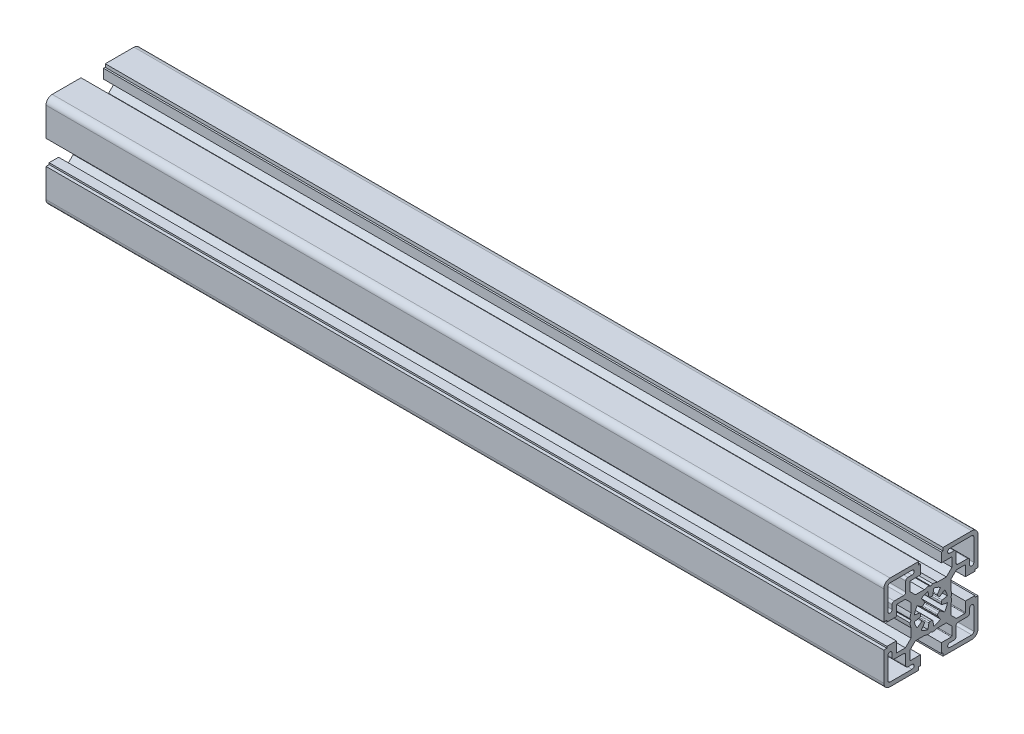
from build123d import *

# Parameters (mm, degrees)
EXTRUDE_1_DEPTH     = 400
CUT_EXTRUDE_1_DEPTH = 401


with BuildPart() as part:
    # Эскиз2 → Бобышка-Вытянуть1 (new body)
    with BuildSketch(Plane(origin=(0, 0, 0), x_dir=(0, 0, -1), z_dir=(1, 0, 0))):
        with BuildLine():
            Line((16.5, 5), (21, 5))
            Line((21, 5), (21, 5.799999))
            Line((21, 5.799999), (22.5, 5.799999))
            Line((22.5, 5.799999), (22.5, 19.5))
            ThreePointArc((22.5, 19.5), (21.621320344, 21.621320344), (19.5, 22.5))
            Line((19.5, 22.5), (5.799999, 22.5))
            Line((5.799999, 22.5), (5.799999, 21))
            Line((5.799999, 21), (5, 21))
            Line((5, 21), (5, 16.5))
            Line((5, 16.5), (9.75, 16.5))
            ThreePointArc((9.75, 16.5), (9.962132034, 16.412132034), (10.05, 16.2))
            Line((10.05, 16.2), (10.05, 12.171320344))
            Line((10.05, 12.171320344), (7.378679656, 9.5))
            Line((7.378679656, 9.5), (3.122498999, 9.5))
            ThreePointArc((3.122498999, 9.5), (2.007620973, 9.796400259), (0.866025404, 9.962429423))
            Line((0.866025404, 9.962429423), (0, 9.462429423))
            Line((0, 9.462429423), (-0.866025404, 9.962429423))
            ThreePointArc((-0.866025404, 9.962429423), (-2.007620973, 9.796400259), (-3.122498999, 9.5))
            Line((-3.122498999, 9.5), (-7.378679656, 9.5))
            Line((-7.378679656, 9.5), (-10.049999, 12.171319344))
            Line((-10.049999, 12.171319344), (-10.049999, 16.2))
            ThreePointArc((-10.049999, 16.2), (-9.962131034, 16.412132034), (-9.749999, 16.5))
            Line((-9.749999, 16.5), (-5, 16.5))
            Line((-5, 16.5), (-5, 21))
            Line((-5, 21), (-5.799999, 21))
            Line((-5.799999, 21), (-5.799999, 22.5))
            Line((-5.799999, 22.5), (-19.5, 22.5))
            ThreePointArc((-19.5, 22.5), (-21.621320344, 21.621320344), (-22.5, 19.5))
            Line((-22.5, 19.5), (-22.5, 5.799999))
            Line((-22.5, 5.799999), (-21, 5.799999))
            Line((-21, 5.799999), (-21, 5))
            Line((-21, 5), (-16.5, 5))
            Line((-16.5, 5), (-16.5, 9.749999))
            ThreePointArc((-16.5, 9.749999), (-16.412132034, 9.962131034), (-16.2, 10.049999))
            Line((-16.2, 10.049999), (-12.171319344, 10.049999))
            Line((-12.171319344, 10.049999), (-9.5, 7.378679656))
            Line((-9.5, 7.378679656), (-9.5, 3.122498999))
            ThreePointArc((-9.5, 3.122498999), (-9.796400259, 2.007620973), (-9.962429423, 0.866025404))
            Line((-9.962429423, 0.866025404), (-9.462429423, 0))
            Line((-9.462429423, 0), (-9.962429423, -0.866025404))
            ThreePointArc((-9.962429423, -0.866025404), (-9.796400259, -2.007620973), (-9.5, -3.122498999))
            Line((-9.5, -3.122498999), (-9.5, -7.378679656))
            Line((-9.5, -7.378679656), (-12.171320344, -10.05))
            Line((-12.171320344, -10.05), (-16.2, -10.05))
            ThreePointArc((-16.2, -10.05), (-16.412132034, -9.962132034), (-16.5, -9.75))
            Line((-16.5, -9.75), (-16.5, -5))
            Line((-16.5, -5), (-21, -5))
            Line((-21, -5), (-21, -5.799999))
            Line((-21, -5.799999), (-22.5, -5.799999))
            Line((-22.5, -5.799999), (-22.5, -19.5))
            ThreePointArc((-22.5, -19.5), (-21.621320344, -21.621320344), (-19.5, -22.5))
            Line((-19.5, -22.5), (-5.799999, -22.5))
            Line((-5.799999, -22.5), (-5.799999, -21))
            Line((-5.799999, -21), (-5, -21))
            Line((-5, -21), (-5, -16.5))
            Line((-5, -16.5), (-9.749999, -16.5))
            ThreePointArc((-9.749999, -16.5), (-9.962131034, -16.412132034), (-10.049999, -16.2))
            Line((-10.049999, -16.2), (-10.049999, -12.171319344))
            Line((-10.049999, -12.171319344), (-7.378679656, -9.5))
            Line((-7.378679656, -9.5), (-3.122498999, -9.5))
            ThreePointArc((-3.122498999, -9.5), (-2.007620973, -9.796400259), (-0.866025404, -9.962429423))
            Line((-0.866025404, -9.962429423), (0, -9.462429423))
            Line((0, -9.462429423), (0.866025404, -9.962429423))
            ThreePointArc((0.866025404, -9.962429423), (2.007620973, -9.796400259), (3.122498999, -9.5))
            Line((3.122498999, -9.5), (7.378679656, -9.5))
            Line((7.378679656, -9.5), (10.05, -12.171320344))
            Line((10.05, -12.171320344), (10.05, -16.2))
            ThreePointArc((10.05, -16.2), (9.962132034, -16.412132034), (9.75, -16.5))
            Line((9.75, -16.5), (5, -16.5))
            Line((5, -16.5), (5, -21))
            Line((5, -21), (5.799999, -21))
            Line((5.799999, -21), (5.799999, -22.5))
            Line((5.799999, -22.5), (19.5, -22.5))
            ThreePointArc((19.5, -22.5), (21.621320344, -21.621320344), (22.5, -19.5))
            Line((22.5, -19.5), (22.5, -5.799999))
            Line((22.5, -5.799999), (21, -5.799999))
            Line((21, -5.799999), (21, -5))
            Line((21, -5), (16.5, -5))
            Line((16.5, -5), (16.5, -9.75))
            ThreePointArc((16.5, -9.75), (16.412132034, -9.962132034), (16.2, -10.05))
            Line((16.2, -10.05), (12.171320344, -10.05))
            Line((12.171320344, -10.05), (9.5, -7.378679656))
            Line((9.5, -7.378679656), (9.5, -3.122498999))
            ThreePointArc((9.5, -3.122498999), (9.796400259, -2.007620973), (9.962429423, -0.866025404))
            Line((9.962429423, -0.866025404), (9.462429423, 0))
            Line((9.462429423, 0), (9.962429423, 0.866025404))
            ThreePointArc((9.962429423, 0.866025404), (9.796400259, 2.007620973), (9.5, 3.122498999))
            Line((9.5, 3.122498999), (9.5, 7.378679656))
            Line((9.5, 7.378679656), (12.171319344, 10.049999))
            Line((12.171319344, 10.049999), (16.2, 10.049999))
            ThreePointArc((16.2, 10.049999), (16.412132034, 9.962131034), (16.5, 9.749999))
            Line((16.5, 9.749999), (16.5, 5))
        make_face()
    extrude(amount=EXTRUDE_1_DEPTH)

    # Эскиз3 → Вырез-Вытянуть1 (cut, through all)
    with BuildSketch(Plane.ZY):
        with BuildLine():
            Line((-0.951109584, 5.394014463), (-1.38918508, 7.878462452))
            ThreePointArc((-1.38918508, 7.878462452), (-3.061467429, 7.391036664), (-4.588611737, 6.553216624))
            Line((-4.588611737, 6.553216624), (-3.14160736, 4.486680308))
            ThreePointArc((-3.14160736, 4.486680308), (-3.055338858, 4.135563126), (-3.228348507, 3.81808369))
            ThreePointArc((-3.228348507, 3.81808369), (-3.535533704, 3.535533704), (-3.81808369, 3.228348507))
            ThreePointArc((-3.81808369, 3.228348507), (-4.135563126, 3.055338858), (-4.486680308, 3.14160736))
            Line((-4.486680308, 3.14160736), (-6.553216624, 4.588611737))
            ThreePointArc((-6.553216624, 4.588611737), (-7.391036664, 3.061467429), (-7.878462452, 1.38918508))
            Line((-7.878462452, 1.38918508), (-5.394014463, 0.951109584))
            ThreePointArc((-5.394014463, 0.951109584), (-5.084736142, 0.763833295), (-4.982580573, 0.417005199))
            ThreePointArc((-4.982580573, 0.417005199), (-5.000000251, 0), (-4.982580573, -0.417005199))
            ThreePointArc((-4.982580573, -0.417005199), (-5.084736142, -0.763833295), (-5.394014463, -0.951109584))
            Line((-5.394014463, -0.951109584), (-7.878461766, -1.389184959))
            ThreePointArc((-7.878461766, -1.389184959), (-7.391036076, -3.06146703), (-6.553216219, -4.588611102))
            Line((-6.553216219, -4.588611102), (-4.486680308, -3.14160736))
            ThreePointArc((-4.486680308, -3.14160736), (-4.135563126, -3.055338858), (-3.81808369, -3.228348507))
            ThreePointArc((-3.81808369, -3.228348507), (-3.535533733, -3.535533675), (-3.22834857, -3.818083636))
            ThreePointArc((-3.22834857, -3.818083636), (-3.055338921, -4.135563118), (-3.141607485, -4.486680327))
            Line((-3.141607485, -4.486680327), (-4.588611972, -6.55321596))
            ThreePointArc((-4.588611972, -6.55321596), (-3.061467529, -7.39103618), (-1.38918499, -7.878462052))
            Line((-1.38918499, -7.878462052), (-0.951109584, -5.394014463))
            ThreePointArc((-0.951109584, -5.394014463), (-0.763833295, -5.084736142), (-0.417005199, -4.982580573))
            ThreePointArc((-0.417005199, -4.982580573), (0, -5.000000251), (0.417005199, -4.982580573))
            ThreePointArc((0.417005199, -4.982580573), (0.763833295, -5.084736142), (0.951109584, -5.394014463))
            Line((0.951109584, -5.394014463), (1.389184959, -7.878461766))
            ThreePointArc((1.389184959, -7.878461766), (3.061467283, -7.391035971), (4.58861155, -6.553215905))
            Line((4.58861155, -6.553215905), (3.141607485, -4.486680327))
            ThreePointArc((3.141607485, -4.486680327), (3.055338921, -4.135563118), (3.22834857, -3.818083636))
            ThreePointArc((3.22834857, -3.818083636), (3.535533704, -3.535533704), (3.818083636, -3.22834857))
            ThreePointArc((3.818083636, -3.22834857), (4.135563118, -3.055338921), (4.486680327, -3.141607485))
            Line((4.486680327, -3.141607485), (6.55321596, -4.588611972))
            ThreePointArc((6.55321596, -4.588611972), (7.39103618, -3.061467529), (7.878462052, -1.38918499))
            Line((7.878462052, -1.38918499), (5.394014463, -0.951109584))
            ThreePointArc((5.394014463, -0.951109584), (5.084736142, -0.763833295), (4.982580573, -0.417005199))
            ThreePointArc((4.982580573, -0.417005199), (5.000000251, 0), (4.982580573, 0.417005199))
            ThreePointArc((4.982580573, 0.417005199), (5.084736142, 0.763833295), (5.394014463, 0.951109584))
            Line((5.394014463, 0.951109584), (7.878462049, 1.389185009))
            ThreePointArc((7.878462049, 1.389185009), (7.391036176, 3.061467538), (6.55321596, 4.588611972))
            Line((6.55321596, 4.588611972), (4.486680327, 3.141607485))
            ThreePointArc((4.486680327, 3.141607485), (4.135563118, 3.055338921), (3.818083636, 3.22834857))
            ThreePointArc((3.818083636, 3.22834857), (3.535533675, 3.535533733), (3.228348507, 3.81808369))
            ThreePointArc((3.228348507, 3.81808369), (3.055338858, 4.135563126), (3.14160736, 4.486680308))
            Line((3.14160736, 4.486680308), (4.588611737, 6.553216624))
            ThreePointArc((4.588611737, 6.553216624), (3.061467429, 7.391036664), (1.38918508, 7.878462452))
            Line((1.38918508, 7.878462452), (0.951109584, 5.394014463))
            ThreePointArc((0.951109584, 5.394014463), (0.763833295, 5.084736142), (0.417005199, 4.982580573))
            ThreePointArc((0.417005199, 4.982580573), (0, 5.000000251), (-0.417005199, 4.982580573))
            ThreePointArc((-0.417005199, 4.982580573), (-0.763833295, 5.084736142), (-0.951109584, 5.394014463))
        make_face()
        with BuildLine():
            Line((-17.5, 12), (-13, 12))
            ThreePointArc((-13, 12), (-12.292894344, 12.292894094), (-12.000002, 13.000000474))
            Line((-12.000002, 13.000000474), (-12, 17.5))
            ThreePointArc((-12, 17.5), (-11.707106781, 18.207106781), (-11, 18.5))
            Line((-11, 18.5), (-9, 18.5))
            ThreePointArc((-9, 18.5), (-8, 19.5), (-9, 20.5))
            Line((-9, 20.5), (-19.5, 20.5))
            ThreePointArc((-19.5, 20.5), (-20.207106781, 20.207106781), (-20.5, 19.5))
            Line((-20.5, 19.5), (-20.5, 9))
            ThreePointArc((-20.5, 9), (-19.5, 8), (-18.5, 9))
            Line((-18.5, 9), (-18.5, 11))
            ThreePointArc((-18.5, 11), (-18.207106781, 11.707106781), (-17.5, 12))
        make_face()
        with BuildLine():
            Line((17.5, 12), (13.000000474, 12.000002))
            ThreePointArc((13.000000474, 12.000002), (12.292894094, 12.292894344), (12, 13))
            Line((12, 13), (12, 17.5))
            ThreePointArc((12, 17.5), (11.707106781, 18.207106781), (11, 18.5))
            Line((11, 18.5), (9, 18.5))
            ThreePointArc((9, 18.5), (8, 19.5), (9, 20.5))
            Line((9, 20.5), (19.5, 20.5))
            ThreePointArc((19.5, 20.5), (20.207106781, 20.207106781), (20.5, 19.5))
            Line((20.5, 19.5), (20.5, 9))
            ThreePointArc((20.5, 9), (19.5, 8), (18.5, 9))
            Line((18.5, 9), (18.5, 11))
            ThreePointArc((18.5, 11), (18.207106781, 11.707106781), (17.5, 12))
        make_face()
        with BuildLine():
            Line((-17.5, -12), (-13.000000474, -12.000002))
            ThreePointArc((-13.000000474, -12.000002), (-12.292894094, -12.292894344), (-12, -13))
            Line((-12, -13), (-12, -17.5))
            ThreePointArc((-12, -17.5), (-11.707106781, -18.207106781), (-11, -18.5))
            Line((-11, -18.5), (-9, -18.5))
            ThreePointArc((-9, -18.5), (-8, -19.5), (-9, -20.5))
            Line((-9, -20.5), (-19.5, -20.5))
            ThreePointArc((-19.5, -20.5), (-20.207106781, -20.207106781), (-20.5, -19.5))
            Line((-20.5, -19.5), (-20.5, -9))
            ThreePointArc((-20.5, -9), (-19.5, -8), (-18.5, -9))
            Line((-18.5, -9), (-18.5, -11))
            ThreePointArc((-18.5, -11), (-18.207106781, -11.707106781), (-17.5, -12))
        make_face()
        with BuildLine():
            Line((19.5, -20.5), (9, -20.5))
            ThreePointArc((9, -20.5), (8, -19.5), (9, -18.5))
            Line((9, -18.5), (11, -18.5))
            ThreePointArc((11, -18.5), (11.707106781, -18.207106781), (12, -17.5))
            Line((12, -17.5), (12.000002, -13.000000474))
            ThreePointArc((12.000002, -13.000000474), (12.292894344, -12.292894094), (13, -12))
            Line((13, -12), (17.5, -12))
            ThreePointArc((17.5, -12), (18.207106781, -11.707106781), (18.5, -11))
            Line((18.5, -11), (18.5, -9))
            ThreePointArc((18.5, -9), (19.5, -8), (20.5, -9))
            Line((20.5, -9), (20.5, -19.5))
            ThreePointArc((20.5, -19.5), (20.207106781, -20.207106781), (19.5, -20.5))
        make_face()
    extrude(amount=-CUT_EXTRUDE_1_DEPTH, mode=Mode.SUBTRACT)


solid = part.part
